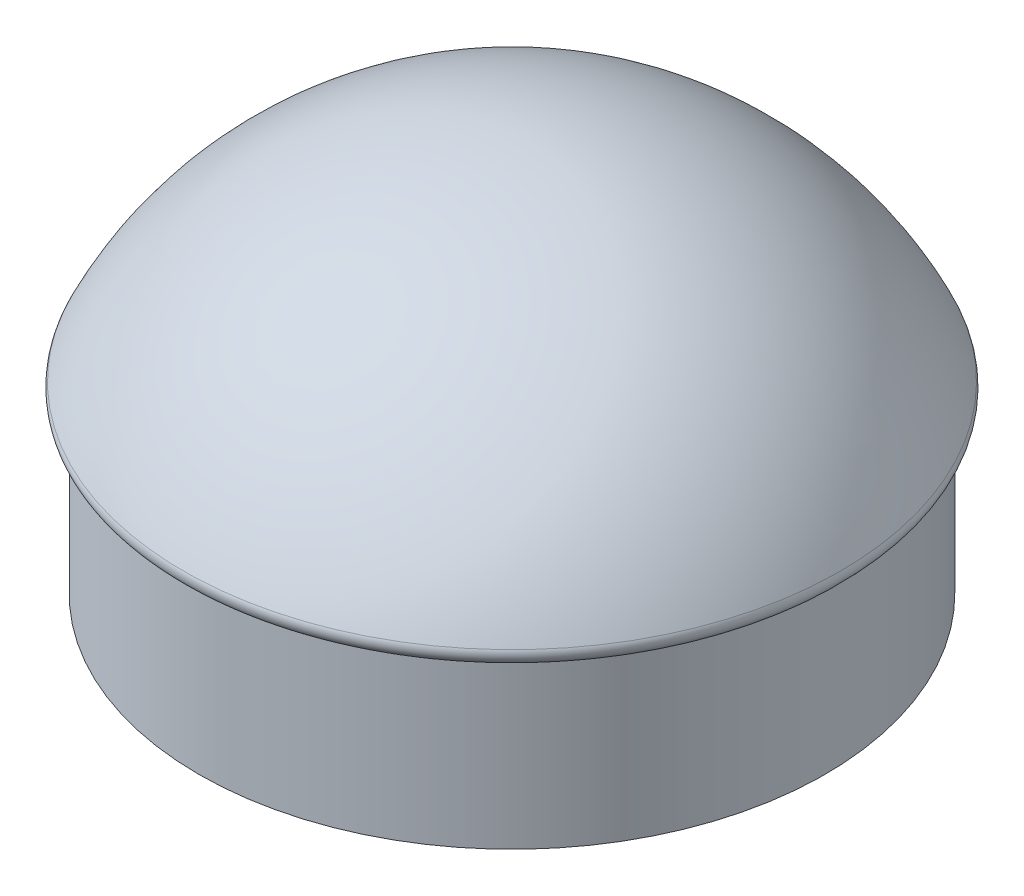
from build123d import *

# Parameters (mm, degrees)
SKETCH1_R           = 140
BOSS_EXTRUDE1_DEPTH = 75


with BuildPart() as part:
    # Sketch1 → Boss-Extrude1 (new body)
    with BuildSketch(Plane(origin=(0, 0, 0), x_dir=(1, 0, 0), z_dir=(0, 1, 0))):
        Circle(SKETCH1_R)
    extrude(amount=BOSS_EXTRUDE1_DEPTH)

    # Sketch3 → Revolve1 (revolve)
    with BuildSketch(Plane(origin=(0, 0, 0), x_dir=(0, 0, -1), z_dir=(1, 0, 0))):
        with BuildLine():
            Line((0, 75), (0, 175))
            ThreePointArc((0, 175), (86.951478261, 149.95274476), (146.851032835, 82.129681361))
            ThreePointArc((146.851032835, 82.129681361), (146.549139029, 77.321232261), (142.327267003, 75))
            Line((142.327267003, 75), (0, 75))
        make_face()
    revolve(axis=Axis((0, 0, 0), (0, 1, 0)))


solid = part.part
